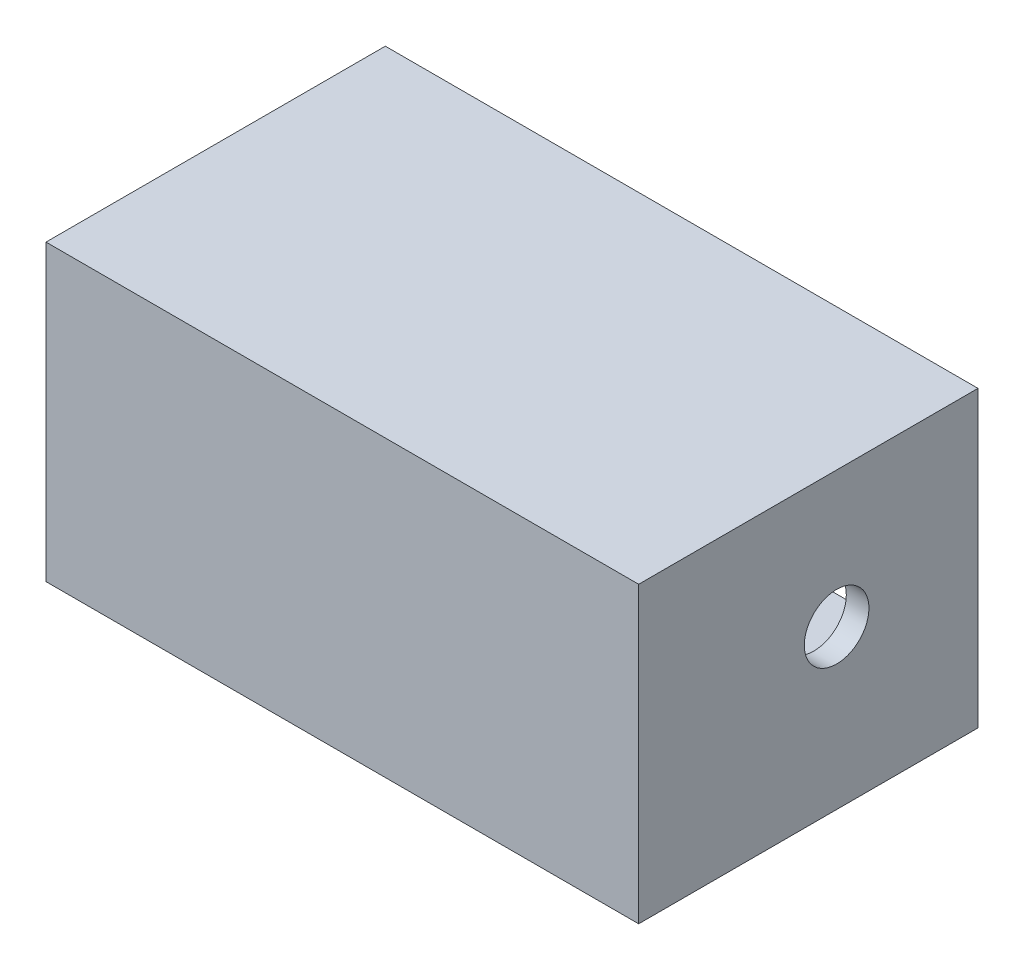
from build123d import *

# Parameters (mm, degrees)
SKETCH1_W           = 262
SKETCH1_H           = 150
BOSS_EXTRUDE1_DEPTH = 20
BOSS_EXTRUDE2_DEPTH = 100
SKETCH3_R           = 14.2875
CUT_EXTRUDE1_DEPTH  = 11
SKETCH4_R           = 14.2875
CUT_EXTRUDE2_DEPTH  = 11
SKETCH5_W           = 262
SKETCH5_H           = 150
BOSS_EXTRUDE4_DEPTH = 10


with BuildPart() as part:
    # Sketch1 → Boss-Extrude1 (new body)
    with BuildSketch(Plane(origin=(0, 0, 0), x_dir=(1, 0, 0), z_dir=(0, 1, 0))):
        with Locations((131, 75)):
            Rectangle(SKETCH1_W, SKETCH1_H)
    extrude(amount=BOSS_EXTRUDE1_DEPTH)

    # Sketch2 → Boss-Extrude2 (add)
    with BuildSketch(Plane(origin=(0, 20, 0), x_dir=(1, 0, 0), z_dir=(0, 1, 0))):
        Polygon((0, 0), (262, 0), (262, 150), (252, 150), (252, 10), (10, 10), (10, 150), (0, 150), align=None)
    extrude(amount=BOSS_EXTRUDE2_DEPTH)

    # Sketch3 → Cut-Extrude1 (cut, through all)
    with BuildSketch(Plane(origin=(10, 0, 0), x_dir=(0, 0, -1), z_dir=(1, 0, 0))):
        with Locations((87.5, 70)):
            Circle(SKETCH3_R)
    extrude(amount=-CUT_EXTRUDE1_DEPTH, mode=Mode.SUBTRACT)

    # Sketch4 → Cut-Extrude2 (cut, through all)
    with BuildSketch(Plane(origin=(252, 0, 0), x_dir=(0, 0, -1), z_dir=(1, 0, 0))):
        with Locations((87.5, 70)):
            Circle(SKETCH4_R)
    extrude(amount=CUT_EXTRUDE2_DEPTH, mode=Mode.SUBTRACT)

    # Sketch5 → Boss-Extrude4 (add)
    with BuildSketch(Plane(origin=(0, 120, 0), x_dir=(1, 0, 0), z_dir=(0, 1, 0))):
        with Locations((131, 75)):
            Rectangle(SKETCH5_W, SKETCH5_H)
    extrude(amount=BOSS_EXTRUDE4_DEPTH)


solid = part.part
